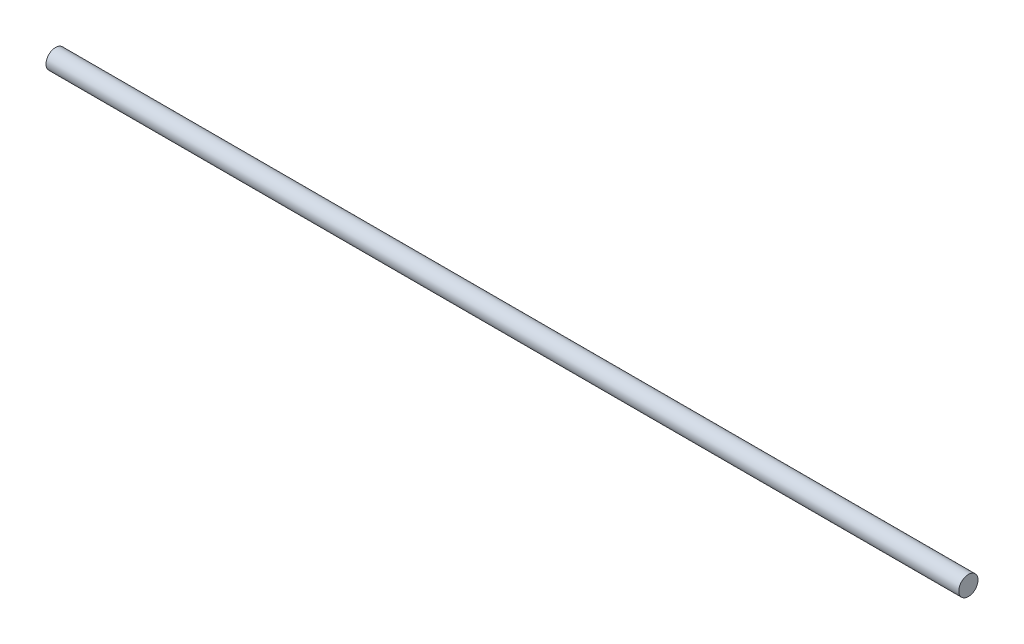
from build123d import *

# Parameters (mm, degrees)
CROQUIS2_R = 13.7


with BuildPart() as part:
    # Barrer1: sweep along a curve in space
    with BuildLine() as barrer1_path:
        Line((0, 0, 0), (-1300, 0, 0))
    # Croquis2 → Barrer1 (sweep)
    with BuildSketch(Plane(origin=(0, 0, 0), x_dir=(0, 0, -1), z_dir=(1, 0, 0))):
        Circle(CROQUIS2_R)
    sweep(path=barrer1_path.line)


solid = part.part
